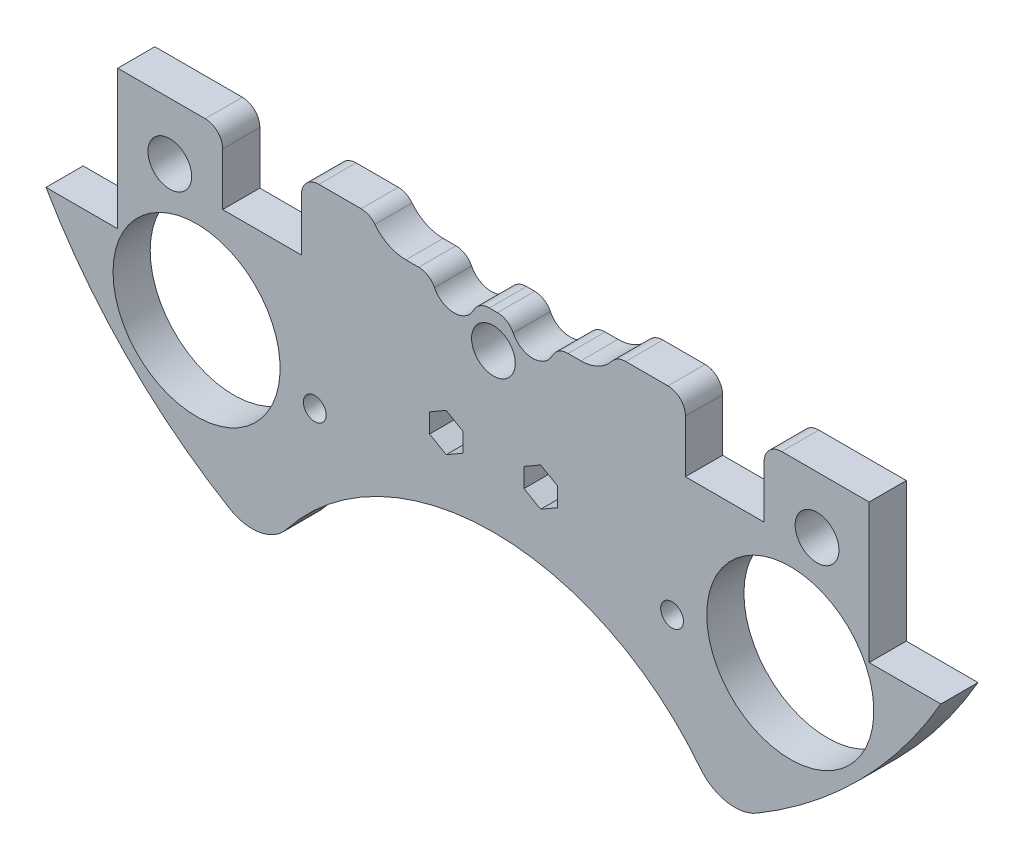
from build123d import *

# Parameters (mm, degrees)
SKETCH1_R                 = 1.651
BOSS_EXTRUDE2_DEPTH       = 5.3975
SKETCH2_R                 = 1.143
CUT_EXTRUDE1_DEPTH        = 6.3975
SKETCH3_R                 = 12.1285
CUT_EXTRUDE2_DEPTH        = 6.3975
SKETCH4_W                 = 28.562713242
SKETCH4_H                 = 11.677503754
BOSS_EXTRUDE3_DEPTH       = 5.3975
SKETCH5_W                 = 216.7214489
SKETCH5_H                 = 130.569220634
CUT_EXTRUDE4_DEPTH        = 6.3975
SKETCH6_R                 = 38.1
CUT_EXTRUDE5_DEPTH        = 60.96
FILLET1_R                 = 6.35
FILLET2_R                 = 6.35
SKETCH102_W               = 11.43
SKETCH102_H               = 10.16
CUT_EXTRUDE101_DEPTH      = 6.3975001
SKETCH158_R               = 1.651
CUT_EXTRUDE157_DEPTH      = 97.79
SKETCH212_R               = 3.175
CUT_EXTRUDE211_DEPTH      = 103.378
CUT_EXTRUDE211_DEPTH_BACK = 48.768
CUT_EXTRUDE104_DEPTH      = 10
FILLET3_R                 = 2.54
SKETCH225_R               = 12.1285
BOSS_EXTRUDE4_DEPTH       = 5.3975
CUT_EXTRUDE224_DEPTH      = 6.3975001


with BuildPart() as part:
    # Sketch1 → Boss-Extrude2 (new body)
    with BuildSketch(Plane.XY):
        with BuildLine():
            Line((-64.964441474, 37.338), (-54.550441474, 37.338))
            Line((-54.550441474, 37.338), (-54.550441474, -37.338))
            Line((-54.550441474, -37.338), (-64.964441474, -37.338))
            ThreePointArc((-64.964441474, -37.338), (0, -74.93), (64.964441474, -37.338))
            Line((64.964441474, -37.338), (54.550441474, -37.338))
            Line((54.550441474, -37.338), (54.550441474, 37.338))
            Line((54.550441474, 37.338), (64.964441474, 37.338))
            ThreePointArc((64.964441474, 37.338), (0, 74.93), (-64.964441474, 37.338))
        make_face()
        with Locations((-46.482, 11.049)):
            Circle(SKETCH1_R, mode=Mode.SUBTRACT)
        with Locations((-21.083270032, 10.795)):
            Circle(SKETCH1_R, mode=Mode.SUBTRACT)
        with Locations((-21.083270032, -10.795)):
            Circle(SKETCH1_R, mode=Mode.SUBTRACT)
        with Locations((-46.482, -11.049)):
            Circle(SKETCH1_R, mode=Mode.SUBTRACT)
        with Locations((46.482, -11.049)):
            Circle(SKETCH1_R, mode=Mode.SUBTRACT)
        with Locations((21.083270032, -10.795)):
            Circle(SKETCH1_R, mode=Mode.SUBTRACT)
        with Locations((21.083270032, 10.795)):
            Circle(SKETCH1_R, mode=Mode.SUBTRACT)
        with Locations((46.482, 11.049)):
            Circle(SKETCH1_R, mode=Mode.SUBTRACT)
    extrude(amount=BOSS_EXTRUDE2_DEPTH)

    # Sketch2 → Cut-Extrude1 (cut, through all)
    with BuildSketch(Plane.XY.offset(5.3975)):
        with Locations((-6.731, 62.23)):
            Circle(SKETCH2_R)
        with Locations((6.731, 62.23)):
            Circle(SKETCH2_R)
    extrude(amount=-CUT_EXTRUDE1_DEPTH, mode=Mode.SUBTRACT)

    # Sketch3 → Cut-Extrude2 (cut, through all)
    with BuildSketch(Plane(origin=(0, 0, 0), x_dir=(-1, 0, 0), z_dir=(0, 0, -1))):
        with Locations((-43.105229381, -43.105229381)):
            Circle(SKETCH3_R)
        with Locations((14.224, -34.29)):
            Circle(SKETCH3_R)
        with Locations((14.224, 34.29)):
            Circle(SKETCH3_R)
        with Locations((-43.105229381, 43.105229381)):
            Circle(SKETCH3_R)
        with Locations((43.105229381, 43.105229381)):
            Circle(SKETCH3_R)
        with Locations((-14.224, 34.29)):
            Circle(SKETCH3_R)
        with Locations((-14.224, -34.29)):
            Circle(SKETCH3_R)
        with Locations((43.105229381, -43.105229381)):
            Circle(SKETCH3_R)
    extrude(amount=-CUT_EXTRUDE2_DEPTH, mode=Mode.SUBTRACT)

    # Sketch4 → Boss-Extrude3 (add)
    with BuildSketch(Plane(origin=(0, 0, 0), x_dir=(-1, 0, 0), z_dir=(0, 0, -1))):
        with Locations((-1.488809975, 62.152540216)):
            Rectangle(SKETCH4_W, SKETCH4_H)
    extrude(amount=-BOSS_EXTRUDE3_DEPTH)

    # Sketch5 → Cut-Extrude4 (cut, through all)
    with BuildSketch(Plane(origin=(0, 0, 0), x_dir=(-1, 0, 0), z_dir=(0, 0, -1))):
        with Locations((23.316688373, 48.139610317)):
            Rectangle(SKETCH5_W, SKETCH5_H)
    extrude(amount=-CUT_EXTRUDE4_DEPTH, mode=Mode.SUBTRACT)

    # Sketch6 → Cut-Extrude5 (cut)
    with BuildSketch(Plane(origin=(0, 0, 0), x_dir=(-1, 0, 0), z_dir=(0, 0, -1))):
        with Locations((0, -86.312058398)):
            Circle(SKETCH6_R)
    extrude(amount=-CUT_EXTRUDE5_DEPTH, mode=Mode.SUBTRACT)

    # Fillet1
    fillet1_edges = [part.edges().sort_by_distance(p)[0] for p in [
        (-33.000960548, -67.271401821, 2.69875),
    ]]
    fillet(fillet1_edges, radius=FILLET1_R)

    # Fillet2
    fillet2_edges = [part.edges().sort_by_distance(p)[0] for p in [
        (33.000960548, -67.271401821, 2.69875),
    ]]
    fillet(fillet2_edges, radius=FILLET2_R)

    # Sketch102 → Cut-Extrude101 (cut, through all)
    with BuildSketch(Plane(origin=(0, 0, 0), x_dir=(-1, 0, 0), z_dir=(0, 0, -1))):
        with Locations((-33.595441474, -22.225)):
            Rectangle(SKETCH102_W, SKETCH102_H)
        with Locations((33.595441474, -22.225)):
            Rectangle(SKETCH102_W, SKETCH102_H)
    extrude(amount=-CUT_EXTRUDE101_DEPTH, mode=Mode.SUBTRACT)

    # Sketch158 → Cut-Extrude157 (cut)
    with BuildSketch(Plane(origin=(30.092005081, 4.08352975, -24.638), x_dir=(-1, 0, 0), z_dir=(0, 0, -1))):
        with Locations((4.154396091, -49.728759131)):
            Circle(SKETCH158_R)
        with Locations((56.02961407, -49.728759131)):
            Circle(SKETCH158_R)
    extrude(amount=-CUT_EXTRUDE157_DEPTH, mode=Mode.SUBTRACT)

    # Sketch212 → Cut-Extrude211 (cut, two sides)
    with BuildSketch(Plane(origin=(30.092005081, 4.08352975, 11.4935), x_dir=(-1, 0, 0), z_dir=(0, 0, -1))) as cut_extrude211_sk:
        with Locations((77.082005081, -29.48352975)):
            Circle(SKETCH212_R)
        with Locations((30.092005081, -29.48352975)):
            Circle(SKETCH212_R)
        with Locations((-16.897994919, -29.48352975)):
            Circle(SKETCH212_R)
    extrude(amount=CUT_EXTRUDE211_DEPTH, mode=Mode.SUBTRACT)
    extrude(cut_extrude211_sk.sketch, amount=-CUT_EXTRUDE211_DEPTH_BACK, mode=Mode.SUBTRACT)

    # Sketch105 → Cut-Extrude104 (cut)
    with BuildSketch(Plane(origin=(0, 0, 0), x_dir=(-1, 0, 0), z_dir=(0, 0, -1))):
        with BuildLine():
            Line((-12.7, -20.32), (-8.89, -20.32))
            ThreePointArc((-8.89, -20.32), (-5.715, -23.495), (-2.54, -20.32))
            Line((-2.54, -20.32), (2.54, -20.32))
            ThreePointArc((2.54, -20.32), (5.715, -23.495), (8.89, -20.32))
            Line((8.89, -20.32), (12.7, -20.32))
            ThreePointArc((12.7, -20.32), (18.415, -14.605), (12.7, -8.89))
            Line((12.7, -8.89), (-12.7, -8.89))
            ThreePointArc((-12.7, -8.89), (-18.415, -14.605), (-12.7, -20.32))
        make_face()
    extrude(amount=-CUT_EXTRUDE104_DEPTH, mode=Mode.SUBTRACT)

    # Fillet3
    fillet3_edges = [part.edges().sort_by_distance(p)[0] for p in [
        (39.310441474, -17.145, 2.69875),
        (27.880441474, -17.145, 2.69875),
        (-27.880441474, -17.145, 2.69875),
        (-39.310441474, -17.145, 2.69875),
        (17.81953367, -17.145, 2.69875),
        (-17.81953367, -17.145, 2.69875),
        (-8.89, -20.32, 2.69875),
        (-2.54, -20.32, 2.69875),
        (2.54, -20.32, 2.69875),
        (8.89, -20.32, 2.69875),
    ]]
    fillet(fillet3_edges, radius=FILLET3_R)

    # Sketch225 → Boss-Extrude4 (add)
    with BuildSketch(Plane(origin=(0, 0, 0), x_dir=(-1, 0, 0), z_dir=(0, 0, -1))):
        with Locations((-14.224, -34.29)):
            Circle(SKETCH225_R)
        with Locations((14.224, -34.29)):
            Circle(SKETCH225_R)
    extrude(amount=-BOSS_EXTRUDE4_DEPTH)

    # Sketch226 → Cut-Extrude224 (cut, through all)
    with BuildSketch(Plane(origin=(0, 0, 0), x_dir=(-1, 0, 0), z_dir=(0, 0, -1))):
        Polygon((4.445, -37.7228538), (4.445, -40.5091462), (6.858, -41.902292399), (9.271, -40.5091462), (9.271, -37.7228538), (6.858, -36.329707601), align=None)
        Polygon((-4.445, -37.7228538), (-6.858, -36.329707601), (-9.271, -37.7228538), (-9.271, -40.5091462), (-6.858, -41.902292399), (-4.445, -40.5091462), align=None)
    extrude(amount=-CUT_EXTRUDE224_DEPTH, mode=Mode.SUBTRACT)


solid = part.part
